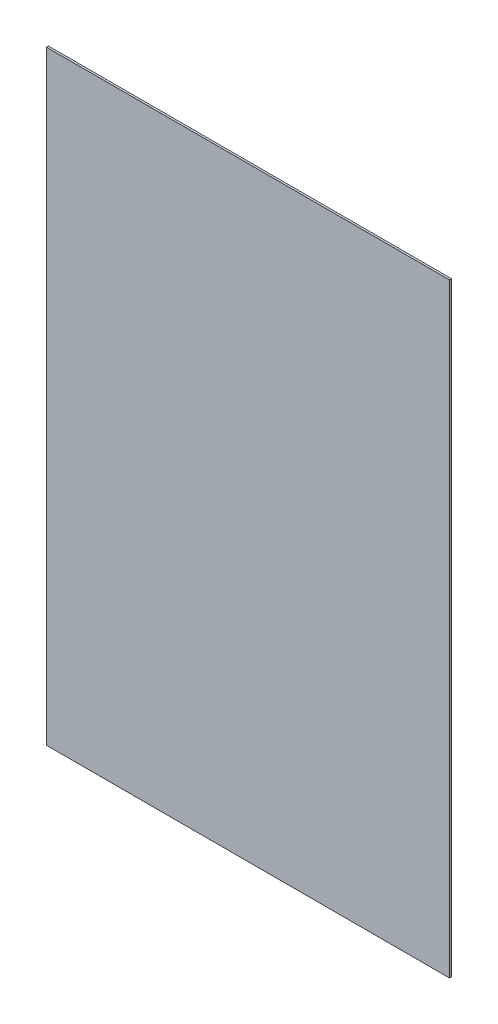
from build123d import *

# Parameters (mm, degrees)
ESQUISSE1_W        = 2000
ESQUISSE1_H        = 3000
BOSS_EXTRU_1_DEPTH = 10


with BuildPart() as part:
    # Esquisse1 → Boss.-Extru.1 (new body)
    with BuildSketch(Plane.XY):
        with Locations((1000, 1500)):
            Rectangle(ESQUISSE1_W, ESQUISSE1_H)
    extrude(amount=BOSS_EXTRU_1_DEPTH)


solid = part.part
